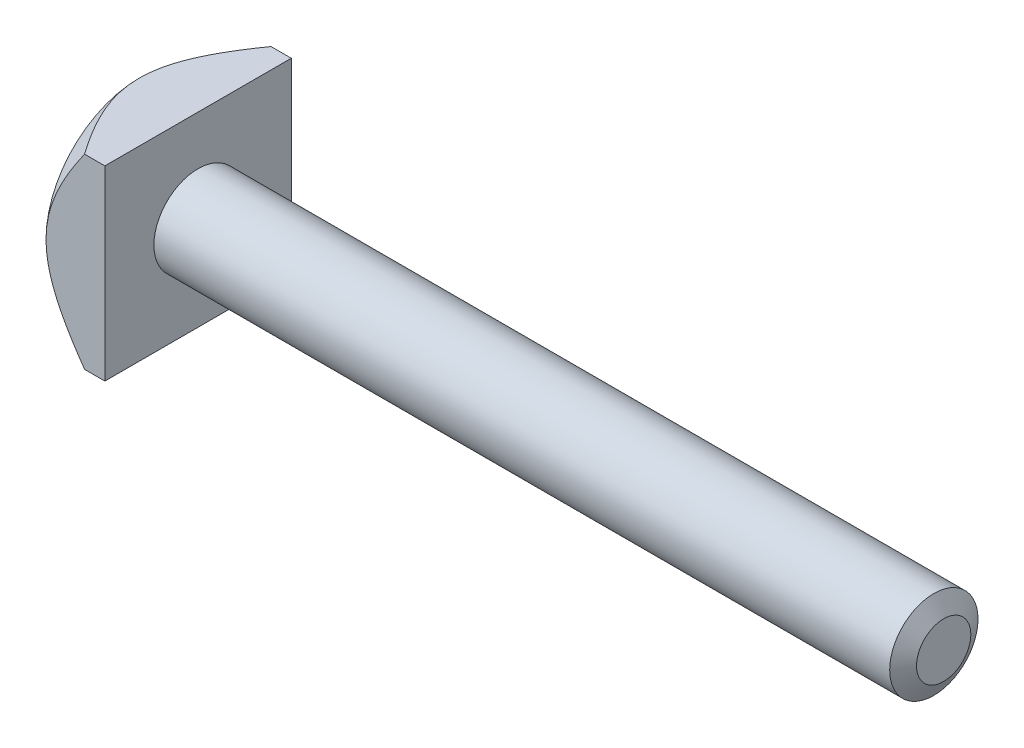
from build123d import *

# Parameters (mm, degrees)
SKETCH1_W           = 19
SKETCH1_H           = 19
BOSS_EXTRUDE1_DEPTH = 6
SKETCH2_R           = 4.5
BOSS_EXTRUDE2_DEPTH = 76
CHAMFER1_SIZE       = 1
CHAMFER1_SIZE2      = 1.732050808
SKETCH3_OUTSIDE_W   = 58.258
SKETCH3_OUTSIDE_H   = 58.258
SKETCH3_OUTSIDE_R   = 9.5
CUT_EXTRUDE1_DEPTH  = 10
CUT_EXTRUDE1_DRAFT  = -45


with BuildPart() as part:
    # Sketch1 → Boss-Extrude1 (new body)
    with BuildSketch(Plane(origin=(0, 0, 0), x_dir=(0, 0, -1), z_dir=(1, 0, 0))):
        Rectangle(SKETCH1_W, SKETCH1_H)
    extrude(amount=BOSS_EXTRUDE1_DEPTH)

    # Sketch2 → Boss-Extrude2 (add)
    with BuildSketch(Plane(origin=(6, 0, 0), x_dir=(0, 0, -1), z_dir=(1, 0, 0))):
        with Locations(Location((0, 0, 0), (0, 0, 180))):  # turned: the seam where the file's is
            Circle(SKETCH2_R)
    extrude(amount=BOSS_EXTRUDE2_DEPTH)

    # Chamfer1
    chamfer1_edges = [part.edges().sort_by_distance(p)[0] for p in [
        (82, 0, -4.5),
    ]]
    chamfer1_side = [part.faces().sort_by_distance(p)[0] for p in [
        (44, 0, -4.5),
    ]]
    chamfer(chamfer1_edges, length=CHAMFER1_SIZE, length2=CHAMFER1_SIZE2, reference=chamfer1_side[0])


with BuildPart() as cut_extrude1_tool:
    # Sketch3 outside → Cut-Extrude1 (with draft: the straight prism first)
    with BuildSketch(Plane.ZY):
        Rectangle(SKETCH3_OUTSIDE_W, SKETCH3_OUTSIDE_H)
        Circle(SKETCH3_OUTSIDE_R, mode=Mode.SUBTRACT)
    extrude(amount=-CUT_EXTRUDE1_DEPTH)
    # Cut-Extrude1: the draft: its side faces are tilted about the plane it starts from
    cut_extrude1_sides = [cut_extrude1_tool.faces().sort_by_distance(p)[0] for p in [
        (5, -29.129, 0),
        (5, 0, 29.129),
        (5, 29.129, 0),
        (5, 0, -29.129),
        (5, 0, -9.5),
    ]]
    draft(cut_extrude1_sides, Plane.ZY, CUT_EXTRUDE1_DRAFT)


with BuildPart() as part_1:
    add(part.part)

    # Cut-Extrude1: cut by cut_extrude1_tool
    add(cut_extrude1_tool.part, mode=Mode.SUBTRACT)


solid = part_1.part
